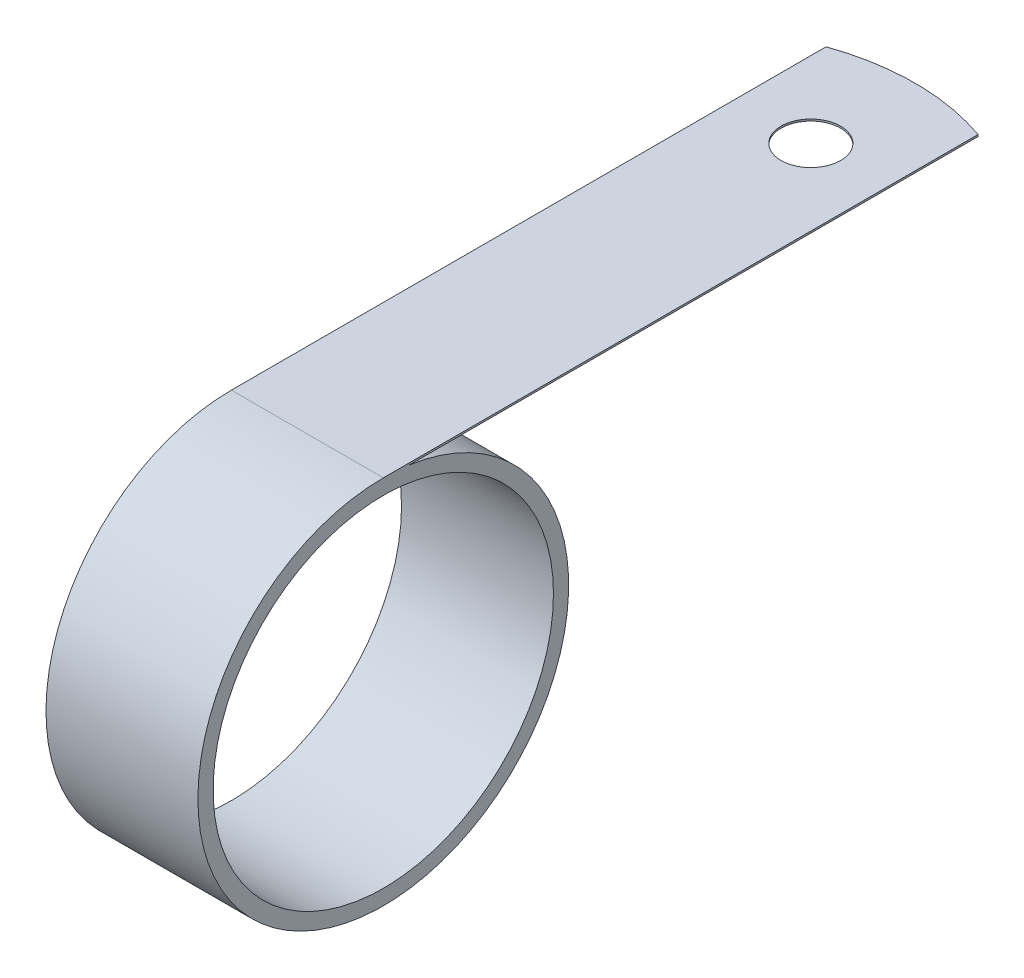
from build123d import *

# Parameters (mm, degrees)
SKETCH1_R           = 14.224
BOSS_EXTRUDE1_DEPTH = 6.35
ONEHOLE_START       = -0.1524
SKETCH2_R           = 2.4892
ONEHOLE_DEPTH       = 0.1524


with BuildPart() as part:
    # Sketch1 → Boss-Extrude1 (new body, symmetric)
    with BuildSketch(Plane(origin=(0, 0, 0), x_dir=(0, 0, -1), z_dir=(1, 0, 0))):
        with BuildLine():
            Line((0, 15.494), (50.8, 15.494))
            Line((50.8, 15.494), (50.8, 15.3416))
            Line((50.8, 15.3416), (2.167797371, 15.3416))
            ThreePointArc((2.167797371, 15.3416), (-1.086573882, -15.45585304), (0, 15.494))
        make_face()
        Circle(SKETCH1_R, mode=Mode.SUBTRACT)
    extrude(amount=BOSS_EXTRUDE1_DEPTH, both=True)

    # Sketch2 → OneHole (cut)
    with BuildSketch(Plane(origin=(0, 15.494, 0), x_dir=(1, 0, 0), z_dir=(0, 1, 0)).offset(ONEHOLE_START)):
        with Locations((0, 42.0878)):
            Circle(SKETCH2_R)
        with BuildLine():
            Line((-6.35, 49.710512242), (-6.35, 51.435))
            Line((-6.35, 51.435), (6.35, 51.435))
            Line((6.35, 51.435), (6.35, 49.710512242))
            ThreePointArc((6.35, 49.710512242), (0, 50.8), (-6.35, 49.710512242))
        make_face()
    extrude(amount=ONEHOLE_DEPTH, mode=Mode.SUBTRACT)


solid = part.part
